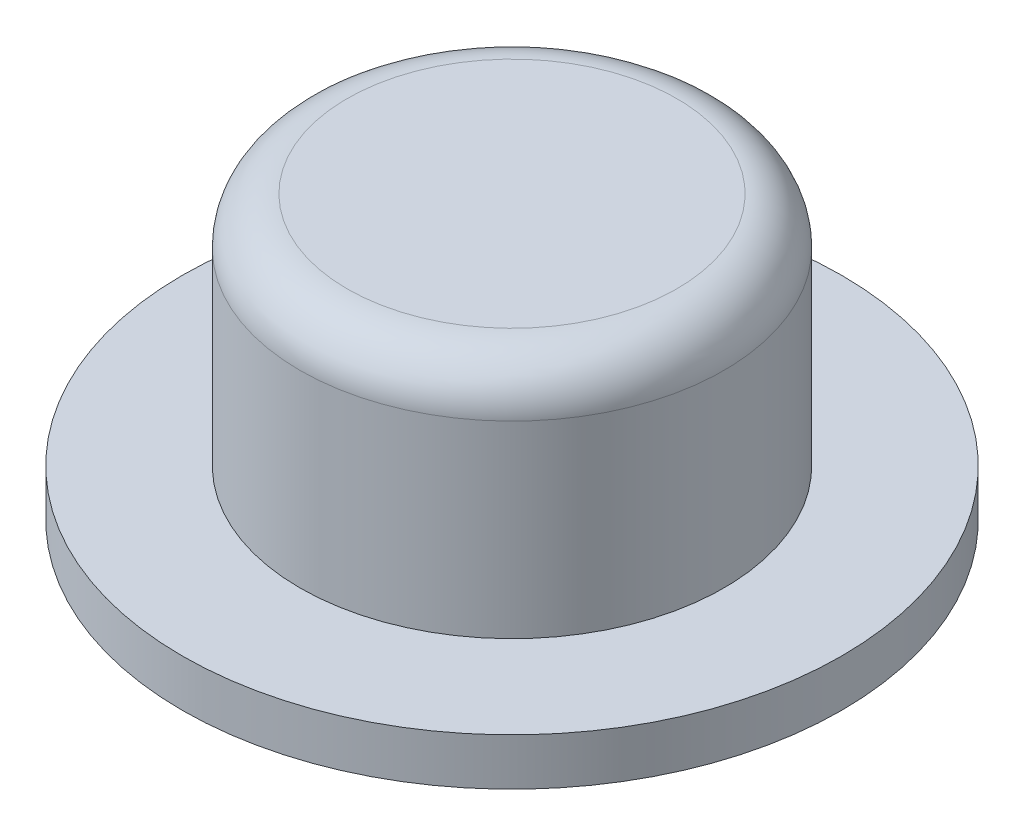
from build123d import *


with BuildPart() as part:
    # Sketch1 → Centre Button (revolve)
    with BuildSketch(Plane.XY):
        with BuildLine():
            Line((0, 6), (0, 0))
            Line((0, 0), (-7, 0))
            Line((-7, 0), (-7, 1))
            Line((-7, 1), (-4.5, 1))
            Line((-4.5, 1), (-4.5, 5))
            ThreePointArc((-4.5, 5), (-4.207106781, 5.707106781), (-3.5, 6))
            Line((-3.5, 6), (0, 6))
        make_face()
    revolve(axis=Axis((0, 6, 0), (0, -1, 0)))


solid = part.part
